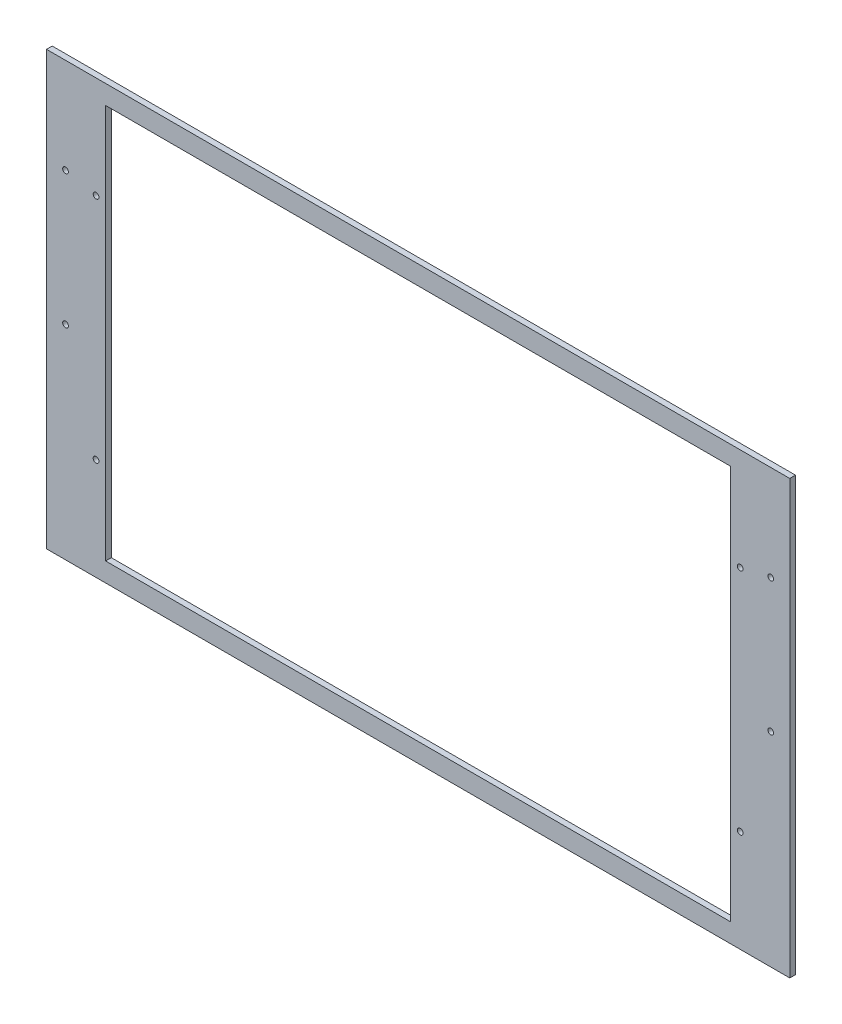
from build123d import *

# Parameters (mm, degrees)
SKETCH1_W           = 390
SKETCH1_H           = 227
SKETCH1_W_2         = 328
SKETCH1_H_2         = 207
BOSS_EXTRUDE1_DEPTH = 3
SKETCH2_R           = 1.5
CUT_EXTRUDE1_DEPTH  = 4
SKETCH3_R           = 1.5
CUT_EXTRUDE2_DEPTH  = 4


with BuildPart() as part:
    # Sketch1 → Boss-Extrude1 (new body)
    with BuildSketch(Plane.XY):
        Rectangle(SKETCH1_W, SKETCH1_H)
        Rectangle(SKETCH1_W_2, SKETCH1_H_2, mode=Mode.SUBTRACT)
    extrude(amount=BOSS_EXTRUDE1_DEPTH)

    # Sketch2 → Cut-Extrude1 (cut, through all)
    with BuildSketch(Plane.XY.offset(3)):
        with Locations((-185, 63.5)):
            Circle(SKETCH2_R)
        with Locations((-185, -6.5)):
            Circle(SKETCH2_R)
        with Locations((185, -6.5)):
            Circle(SKETCH2_R)
        with Locations((185, 63.5)):
            Circle(SKETCH2_R)
    extrude(amount=-CUT_EXTRUDE1_DEPTH, mode=Mode.SUBTRACT)

    # Sketch3 → Cut-Extrude2 (cut, through all)
    with BuildSketch(Plane.XY.offset(3)):
        with Locations((-169, 60)):
            Circle(SKETCH3_R)
        with Locations((-169, -60)):
            Circle(SKETCH3_R)
        with Locations((169, -60)):
            Circle(SKETCH3_R)
        with Locations((169, 60)):
            Circle(SKETCH3_R)
    extrude(amount=-CUT_EXTRUDE2_DEPTH, mode=Mode.SUBTRACT)


solid = part.part
